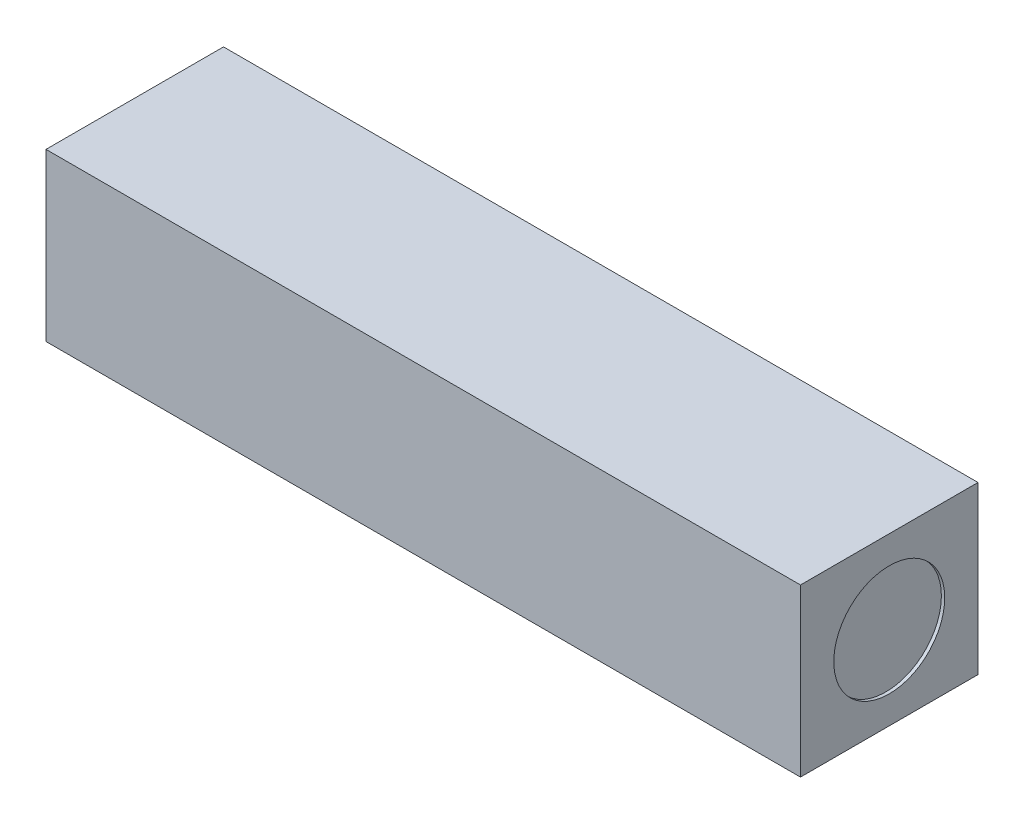
from build123d import *

# Parameters (mm, degrees)
CROQUIS1_W              = 34
CROQUIS1_H              = 8
SALIENTE_EXTRUIR1_DEPTH = 7.5
CROQUIS2_R              = 2.5
CORTAR_EXTRUIR1_DEPTH   = 0.15


with BuildPart() as part:
    # Croquis1 → Saliente-Extruir1 (new body)
    with BuildSketch(Plane(origin=(0, 0, 0), x_dir=(1, 0, 0), z_dir=(0, 1, 0))):
        Rectangle(CROQUIS1_W, CROQUIS1_H)
    extrude(amount=SALIENTE_EXTRUIR1_DEPTH)

    # Croquis2 → Cortar-Extruir1 (cut)
    with BuildSketch(Plane(origin=(17, 0, 0), x_dir=(0, 0, -1), z_dir=(1, 0, 0))):
        with Locations((0, 3.75)):
            Circle(CROQUIS2_R)
    extrude(amount=-CORTAR_EXTRUIR1_DEPTH, mode=Mode.SUBTRACT)


solid = part.part
